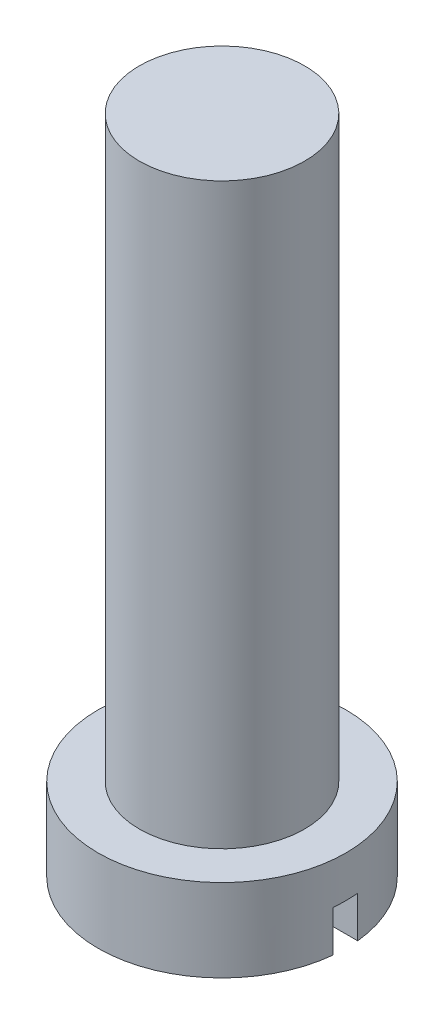
from build123d import *

# Parameters (mm, degrees)
SKETCH1_R           = 3
BOSS_EXTRUDE1_DEPTH = 2
SKETCH2_R           = 2
BOSS_EXTRUDE2_DEPTH = 14
CUT_EXTRUDE2_DEPTH  = 1


with BuildPart() as part:
    # Sketch1 → Boss-Extrude1 (new body)
    with BuildSketch(Plane(origin=(0, 0, 0), x_dir=(1, 0, 0), z_dir=(0, 1, 0))):
        Circle(SKETCH1_R)
    extrude(amount=BOSS_EXTRUDE1_DEPTH)

    # Sketch2 → Boss-Extrude2 (add)
    with BuildSketch(Plane(origin=(0, 2, 0), x_dir=(1, 0, 0), z_dir=(0, 1, 0))):
        Circle(SKETCH2_R)
    extrude(amount=BOSS_EXTRUDE2_DEPTH)

    # Sketch3 → Cut-Extrude2 (cut)
    with BuildSketch(Plane.XZ):
        Polygon((0, 0.3), (3.344738487, 0.3), (3.344738487, 0), (3.344738487, -0.3), (0, -0.3), (-3.50820315, -0.3), (-3.50820315, 0), (-3.50820315, 0.3), align=None)
    extrude(amount=-CUT_EXTRUDE2_DEPTH, mode=Mode.SUBTRACT)


solid = part.part
